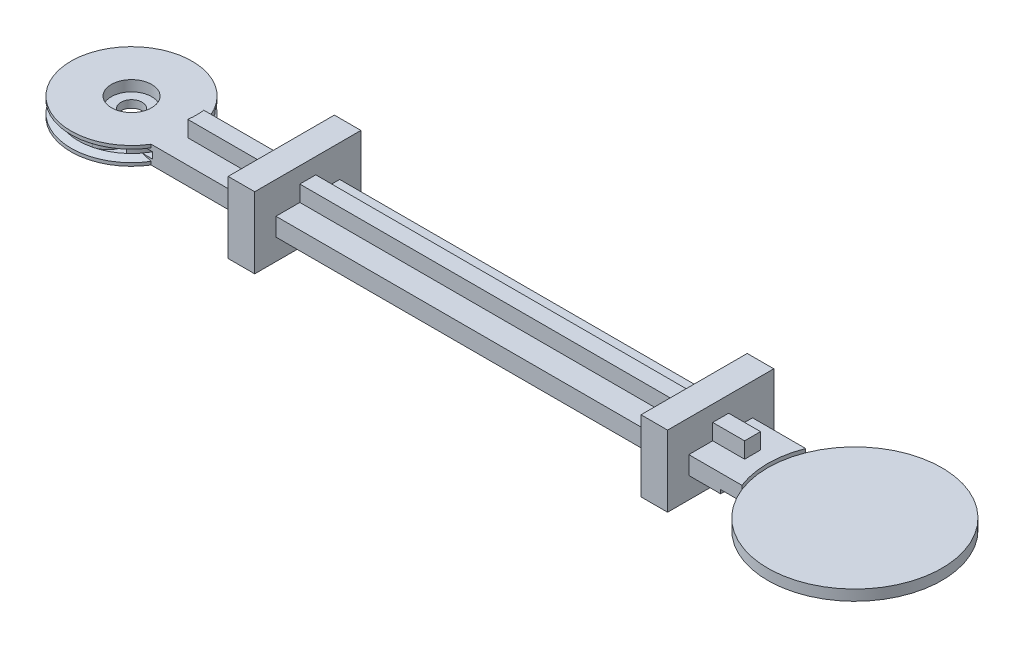
from build123d import *

# Parameters (mm, degrees)
SKETCH1_R                      = 5
BOSS_EXTRUDE1_DEPTH            = 1.7
EP_CABLESLOT_DEPTH             = 0.6
SKETCH4_R                      = 1.9
EP_BALLBEARINGSLOT_DEPTH       = 1
SKETCH5_R                      = 1
EP_SHAFTHOLE_DEPTH             = 0.7
BOSS_EXTRUDE2_START            = -0.85
BOSS_EXTRUDE2_DEPTH            = 1.7
HUMERUSCLEARANCECUT_DEPTH      = 1.7
CABLECLEARANCECUT_DEPTH        = 0.6
SKETCH6_3_R                    = 8.2
MAINPLATE_DEPTH                = 0.5
FINGERPULLEYCLEARANCECUT_DEPTH = 0.35
SKETCH10_W                     = 2.5
SKETCH10_H                     = 10
BLOCK1_DEPTH                   = 3
BLOCK1_DEPTH_BACK              = 3.7
SKETCH13_W                     = 2.5
SKETCH13_H                     = 10
BLOCK2_DEPTH                   = 3
BLOCK2_DEPTH_BACK              = 3.7
SKETCH14_W                     = 36.371319344
SKETCH14_H                     = 1.5
SKETCH14_W_2                   = 5.5
STIFFENERRIB_DEPTH             = 1.5
STIFFENERRIB_DEPTH_BACK        = 3.2


with BuildPart() as part:
    # Sketch1 → Boss-Extrude1 (new body)
    with BuildSketch(Plane(origin=(0, 0, 0), x_dir=(1, 0, 0), z_dir=(0, 1, 0))):
        Circle(SKETCH1_R)
    extrude(amount=BOSS_EXTRUDE1_DEPTH)

    # Sketch2 → Revolve1 (revolve)
    with BuildSketch(Plane.XY):
        Polygon((5, 1.7), (5, 1.15), (5.7, 1.4), (5.7, 1.7), align=None)
        Polygon((5, 0.55), (5, 0), (5.7, 0), (5.7, 0.3), align=None)
    revolve(axis=Axis((0, 1.7, 0), (0, -1, 0)))

    # Sketch3 → EP_CableSlot (cut)
    with BuildSketch(Plane(origin=(0, 0.55, 0), x_dir=(1, 0, 0), z_dir=(0, 1, 0))):
        with BuildLine():
            ThreePointArc((1.166666667, -4.861984049), (2.300738274, -4.439212024), (3.3, -3.756327994))
            Line((3.3, -3.756327994), (3.3, 3.756327994))
            ThreePointArc((3.3, 3.756327994), (2.300738274, 4.439212024), (1.166666667, 4.861984049))
            ThreePointArc((1.166666667, 4.861984049), (2.270562532, 4.155468804), (2.7, 2.917190429))
            Line((2.7, 2.917190429), (2.7, -2.917190429))
            ThreePointArc((2.7, -2.917190429), (2.270562532, -4.155468804), (1.166666667, -4.861984049))
        make_face()
    extrude(amount=EP_CABLESLOT_DEPTH, mode=Mode.SUBTRACT)

    # Sketch4 → EP_BallBearingSlot (cut)
    with BuildSketch(Plane(origin=(0, 1.7, 0), x_dir=(1, 0, 0), z_dir=(0, 1, 0))):
        Circle(SKETCH4_R)
    extrude(amount=-EP_BALLBEARINGSLOT_DEPTH, mode=Mode.SUBTRACT)

    # Sketch5 → EP_ShaftHole (cut)
    with BuildSketch(Plane(origin=(0, 0.7, 0), x_dir=(1, 0, 0), z_dir=(0, 1, 0))):
        Circle(SKETCH5_R)
    extrude(amount=-EP_SHAFTHOLE_DEPTH, mode=Mode.SUBTRACT)

    # Sketch6 → Boss-Extrude2 (add)
    with BuildSketch(Plane(origin=(0, 0.85, 0), x_dir=(1, 0, 0), z_dir=(0, 1, 0)).offset(BOSS_EXTRUDE2_START)):
        with BuildLine():
            ThreePointArc((4, 3), (5, 0), (4, -3))
            Line((4, -3), (60.468486389, -3))
            ThreePointArc((60.468486389, -3), (59.9, 0), (60.468486389, 3))
            Line((60.468486389, 3), (4, 3))
        make_face()
    extrude(amount=BOSS_EXTRUDE2_DEPTH)

    # Sketch8 → HumerusClearanceCut (cut)
    with BuildSketch(Plane(origin=(0, 1.7, 0), x_dir=(1, 0, 0), z_dir=(0, 1, 0))):
        with BuildLine():
            ThreePointArc((4.846648326, 3), (5.22695702, 2.273525963), (5.499090834, 1.5))
            Line((5.499090834, 1.5), (11.499090834, 1.5))
            ThreePointArc((11.499090834, 1.5), (12.999090834, 1.901923789), (14.097167045, 3))
            Line((14.097167045, 3), (4.846648326, 3))
        make_face()
    extrude(amount=-HUMERUSCLEARANCECUT_DEPTH, mode=Mode.SUBTRACT)

    # Sketch11 → CableClearanceCut (cut)
    with BuildSketch(Plane(origin=(0, 0.55, 0), x_dir=(1, 0, 0), z_dir=(0, 1, 0))):
        with BuildLine():
            Line((8.999090834, 1.5), (5.499090834, 1.5))
            ThreePointArc((5.499090834, 1.5), (5.641017612, -0.817875483), (4.846648326, -3))
            ThreePointArc((4.846648326, -3), (4.563342119, -3.415539299), (4.2445102, -3.804488555))
            Line((4.2445102, -3.804488555), (8.999090834, 1.5))
        make_face()
        with BuildLine():
            ThreePointArc((4.846648326, -3), (5.641017612, -0.817875483), (5.499090834, 1.5))
            ThreePointArc((5.499090834, 1.5), (5.22695702, 2.273525963), (4.846648326, 3))
            Line((4.846648326, 3), (4, 3))
            ThreePointArc((4, 3), (5, 0), (4, -3))
            Line((4, -3), (4.846648326, -3))
        make_face()
    extrude(amount=CABLECLEARANCECUT_DEPTH, mode=Mode.SUBTRACT)

    # Sketch6_3 → MainPlate (add, symmetric)
    with BuildSketch(Plane(origin=(0, 0.85, 0), x_dir=(1, 0, 0), z_dir=(0, 1, 0))):
        with Locations((68.1, 0)):
            Circle(SKETCH6_3_R)
    extrude(amount=MAINPLATE_DEPTH, both=True)

    # Sketch12 → FingerPulleyClearanceCut (cut)
    with BuildSketch(Plane(origin=(0, 0, 0), x_dir=(1, 0, 0), z_dir=(0, 1, 0))):
        with BuildLine():
            ThreePointArc((60.468486389, -3), (59.9, 0), (60.468486389, 3))
            Line((60.468486389, 3), (58.468486389, 3))
            Line((58.468486389, 3), (58.468486389, -3))
            Line((58.468486389, -3), (60.468486389, -3))
        make_face()
    extrude(amount=FINGERPULLEYCLEARANCECUT_DEPTH, mode=Mode.SUBTRACT)

    # Sketch10 → Block1 (add, two sides)
    with BuildSketch(Plane(origin=(0, 1.7, 0), x_dir=(1, 0, 0), z_dir=(0, 1, 0))) as block1_sk:
        with Locations((15.347167045, 0)):
            Rectangle(SKETCH10_W, SKETCH10_H)
    extrude(amount=BLOCK1_DEPTH)
    extrude(block1_sk.sketch, amount=-BLOCK1_DEPTH_BACK)

    # Sketch13 → Block2 (add, two sides)
    with BuildSketch(Plane(origin=(0, 1.7, 0), x_dir=(1, 0, 0), z_dir=(0, 1, 0))) as block2_sk:
        with Locations((54.218486389, 0)):
            Rectangle(SKETCH13_W, SKETCH13_H)
    extrude(amount=BLOCK2_DEPTH)
    extrude(block2_sk.sketch, amount=-BLOCK2_DEPTH_BACK)

    # Sketch14 → StiffenerRib (add, two sides)
    with BuildSketch(Plane(origin=(0, 1.7, 0), x_dir=(1, 0, 0), z_dir=(0, 1, 0))) as stiffenerrib_sk:
        with BuildLine():
            Line((16.597167045, -0.75), (16.597167045, 0.75))
            Line((16.597167045, 0.75), (6.053717866, 0.75))
            ThreePointArc((6.053717866, 0.75), (6.1, 0), (6.053717866, -0.75))
            Line((6.053717866, -0.75), (16.597167045, -0.75))
        make_face()
        with Locations((34.782826717, 0)):
            Rectangle(SKETCH14_W, SKETCH14_H)
        with Locations((55.718486389, 0)):
            Rectangle(SKETCH14_W_2, SKETCH14_H)
    extrude(amount=STIFFENERRIB_DEPTH)
    extrude(stiffenerrib_sk.sketch, amount=-STIFFENERRIB_DEPTH_BACK)


solid = part.part
